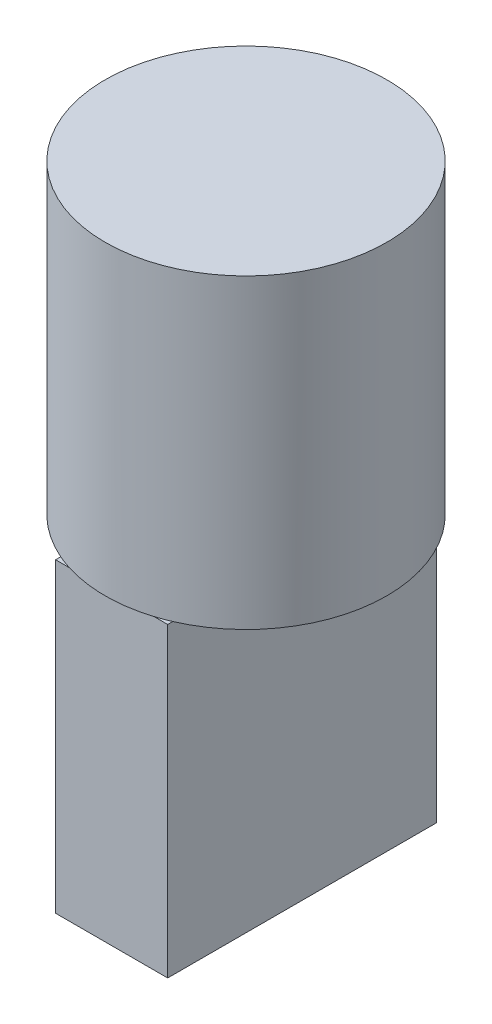
from build123d import *

# Parameters (mm, degrees)
SKETCH_1_R      = 19.32
EXTRUDE_1_DEPTH = 42
SKETCH_2_W      = 15.375163756
SKETCH_2_H      = 36.857684224
EXTRUDE_2_DEPTH = 42


with BuildPart() as part:
    # Эскиз1 → Бобышка-Вытянуть1 (new body)
    with BuildSketch(Plane(origin=(0, 0, 0), x_dir=(1, 0, 0), z_dir=(0, 1, 0))):
        Circle(SKETCH_1_R)
    extrude(amount=EXTRUDE_1_DEPTH)

    # Эскиз2 → Бобышка-Вытянуть2 (add)
    with BuildSketch(Plane.XZ):
        Rectangle(SKETCH_2_W, SKETCH_2_H)
    extrude(amount=EXTRUDE_2_DEPTH)


solid = part.part
